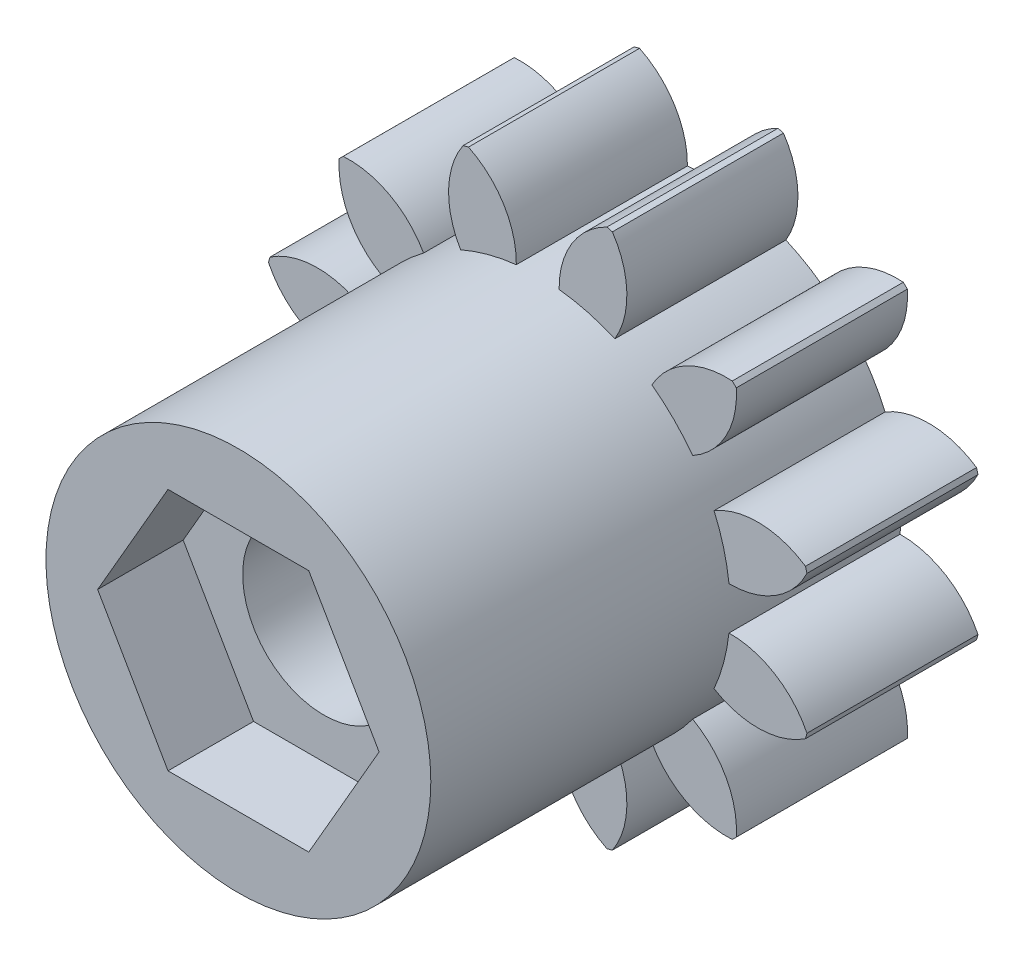
from build123d import *

# Parameters (mm, degrees)
SKETCH1_R           = 6.5
SKETCH1_R_2         = 1
BOSS_EXTRUDE1_DEPTH = 4
CUT_EXTRUDE2_DEPTH  = 11.024968828
CIRPATTERN2_COUNT   = 12
SKETCH11_R          = 4.5
BOSS_EXTRUDE2_DEPTH = 11
CUT_EXTRUDE3_START  = 11
CUT_EXTRUDE3_DEPTH  = 2
SKETCH13_R          = 1.9
CUT_EXTRUDE4_DEPTH  = 15.151353444


with BuildPart() as part:
    # Sketch1 → Boss-Extrude1 (new body)
    with BuildSketch(Plane.XY):
        Circle(SKETCH1_R)
        Circle(SKETCH1_R_2, mode=Mode.SUBTRACT)
    extrude(amount=BOSS_EXTRUDE1_DEPTH)

    # Sketch4 → Cut-Extrude2 (cut, through all)
    with BuildSketch(Plane.XY):
        with BuildLine():
            ThreePointArc((-0.500194414, 4.472114215), (0, 4.5), (0.500194414, 4.472114215))
            ThreePointArc((0.500194414, 4.472114215), (1.113314535, 5.941215952), (2.604960982, 6.497243899))
            ThreePointArc((2.604960982, 6.497243899), (0, 7), (-2.604960982, 6.497243899))
            ThreePointArc((-2.604960982, 6.497243899), (-1.123395838, 5.950848366), (-0.5, 4.5))
            ThreePointArc((-0.5, 4.5), (-0.500048604, 4.486056768), (-0.500194414, 4.472114215))
        make_face()
    cut_extrude2 = extrude(amount=CUT_EXTRUDE2_DEPTH, mode=Mode.SUBTRACT)

    # CirPattern2: Cut-Extrude2 ×12 about axis
    cirpattern2_axis = Axis((0, 0, 4), (0, 0, -1))
    for i in range(1, CIRPATTERN2_COUNT):
        add(cut_extrude2.rotate(cirpattern2_axis, i * 360 / CIRPATTERN2_COUNT), mode=Mode.SUBTRACT)

    # Sketch11 → Boss-Extrude2 (add)
    with BuildSketch(Plane.XY):
        Circle(SKETCH11_R)
    extrude(amount=BOSS_EXTRUDE2_DEPTH)

    # Sketch12 → Cut-Extrude3 (cut)
    with BuildSketch(Plane.XY.offset(CUT_EXTRUDE3_START)):
        Polygon((3.290896534, 0), (1.645448267, 2.85), (-1.645448267, 2.85), (-3.290896534, 0), (-1.645448267, -2.85), (1.645448267, -2.85), align=None)
    extrude(amount=-CUT_EXTRUDE3_DEPTH, mode=Mode.SUBTRACT)

    # Sketch13 → Cut-Extrude4 (cut, through all)
    with BuildSketch(Plane.XY):
        Circle(SKETCH13_R)
    extrude(amount=CUT_EXTRUDE4_DEPTH, mode=Mode.SUBTRACT)


solid = part.part
